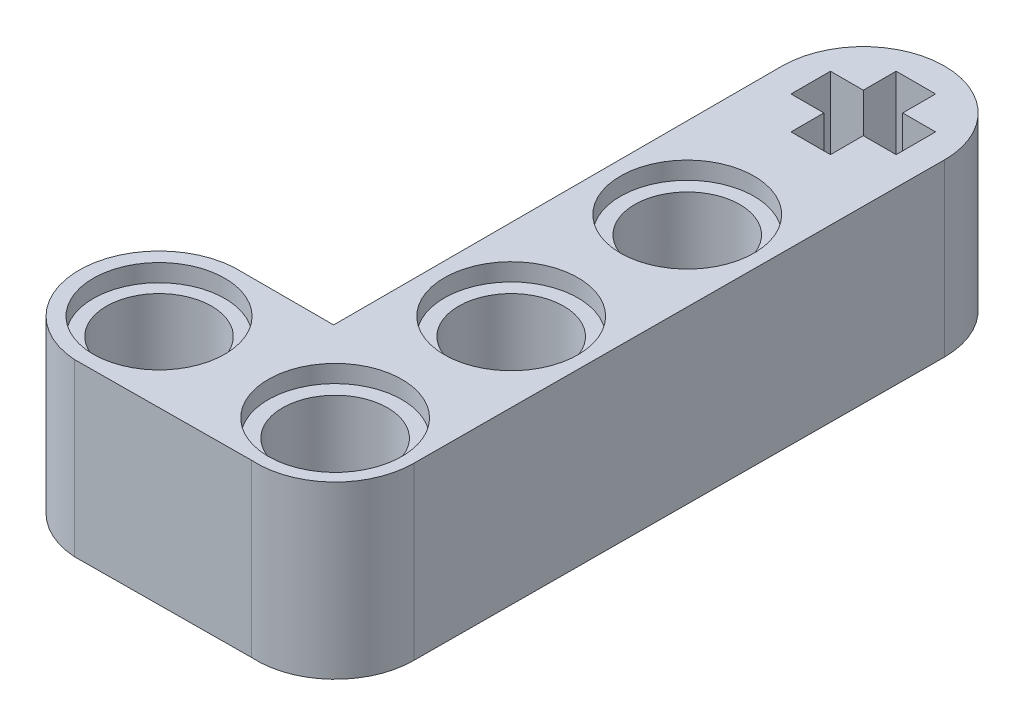
from build123d import *

# Parameters (mm, degrees)
SKETCH1_R           = 2.4
BOSS_EXTRUDE2_DEPTH = 7.8
SKETCH2_R           = 3.005
SKETCH2_R_2         = 3.05
CUT_EXTRUDE1_DEPTH  = 0.8
SKETCH3_R           = 3.05
CUT_EXTRUDE2_DEPTH  = 0.8


with BuildPart() as part:
    # Sketch1 → Boss-Extrude2 (new body)
    with BuildSketch(Plane(origin=(0, 0, 0), x_dir=(1, 0, 0), z_dir=(0, 1, 0))):
        with BuildLine():
            Line((-3.723198341, 3.643010683), (0.380925068, 3.643010683))
            Line((0.380925068, 3.643010683), (0.380925068, 24.12))
            ThreePointArc((0.380925068, 24.12), (4.090929192, 27.830004128), (7.800933325, 24.120000008))
            Line((7.800933325, 24.120000008), (7.680923984, 0.007228348))
            ThreePointArc((7.680923984, 0.007228348), (6.551552066, -2.614086822), (3.866782865, -3.582997801))
            Line((3.866782865, -3.582997801), (-4.174942755, -3.643002442))
            ThreePointArc((-4.174942755, -3.643002442), (-7.592081486, 0.225872463), (-3.723198341, 3.643010683))
        make_face()
        with Locations((-3.949070804, 0)):
            Circle(SKETCH1_R, mode=Mode.SUBTRACT)
        with Locations((4.090929196, 0)):
            Circle(SKETCH1_R, mode=Mode.SUBTRACT)
        with Locations((4.090929196, 8.04)):
            Circle(SKETCH1_R, mode=Mode.SUBTRACT)
        with Locations((4.090929196, 16.08)):
            Circle(SKETCH1_R, mode=Mode.SUBTRACT)
        Polygon((3.190929196, 26.52), (4.990929196, 26.52), (4.990929196, 25.02), (6.490929196, 25.02), (6.490929196, 23.22), (4.990929196, 23.22), (4.990929196, 21.72), (3.190929196, 21.72), (3.190929196, 23.22), (1.690929196, 23.22), (1.690929196, 25.02), (3.190929196, 25.02), align=None, mode=Mode.SUBTRACT)
    extrude(amount=BOSS_EXTRUDE2_DEPTH)

    # Sketch2 → Cut-Extrude1 (cut)
    with BuildSketch(Plane(origin=(0, 7.8, 0), x_dir=(1, 0, 0), z_dir=(0, 1, 0))):
        with Locations((-3.949070804, 0)):
            Circle(SKETCH2_R)
        with Locations((4.090929196, 0)):
            Circle(SKETCH2_R_2)
        with Locations((4.090929196, 8.04)):
            Circle(SKETCH2_R_2)
        with Locations((4.090929196, 16.08)):
            Circle(SKETCH2_R_2)
    extrude(amount=-CUT_EXTRUDE1_DEPTH, mode=Mode.SUBTRACT)

    # Sketch3 → Cut-Extrude2 (cut)
    with BuildSketch(Plane.XZ):
        with Locations((-3.949070804, 0)):
            Circle(SKETCH3_R)
        with Locations((4.090929196, 0)):
            Circle(SKETCH3_R)
        with Locations((4.090929196, -8.04)):
            Circle(SKETCH3_R)
        with Locations((4.090929196, -16.08)):
            Circle(SKETCH3_R)
    extrude(amount=-CUT_EXTRUDE2_DEPTH, mode=Mode.SUBTRACT)


solid = part.part
